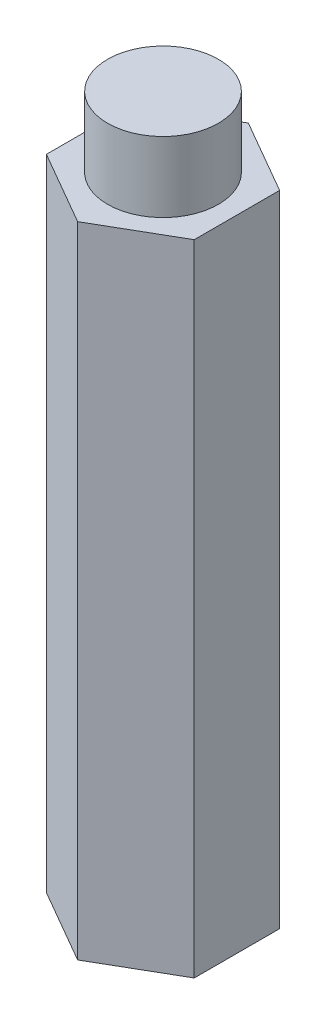
from build123d import *

# Parameters (mm, degrees)
BOSS_EXTRUDE1_DEPTH = 54.9275
SKETCH2_R           = 4.7625
BOSS_EXTRUDE2_DEPTH = 60.96


with BuildPart() as part:
    # Sketch1 → Boss-Extrude1 (new body)
    with BuildSketch(Plane(origin=(0, 0, 0), x_dir=(1, 0, 0), z_dir=(0, 1, 0))):
        Polygon((6.35, -3.666174209), (6.35, 3.666174209), (0, 7.332348419), (-6.35, 3.666174209), (-6.35, -3.666174209), (0, -7.332348419), align=None)
    extrude(amount=BOSS_EXTRUDE1_DEPTH)

    # Sketch2 → Boss-Extrude2 (add)
    with BuildSketch(Plane(origin=(0, 0, 0), x_dir=(1, 0, 0), z_dir=(0, 1, 0))):
        Circle(SKETCH2_R)
    extrude(amount=BOSS_EXTRUDE2_DEPTH)


solid = part.part
